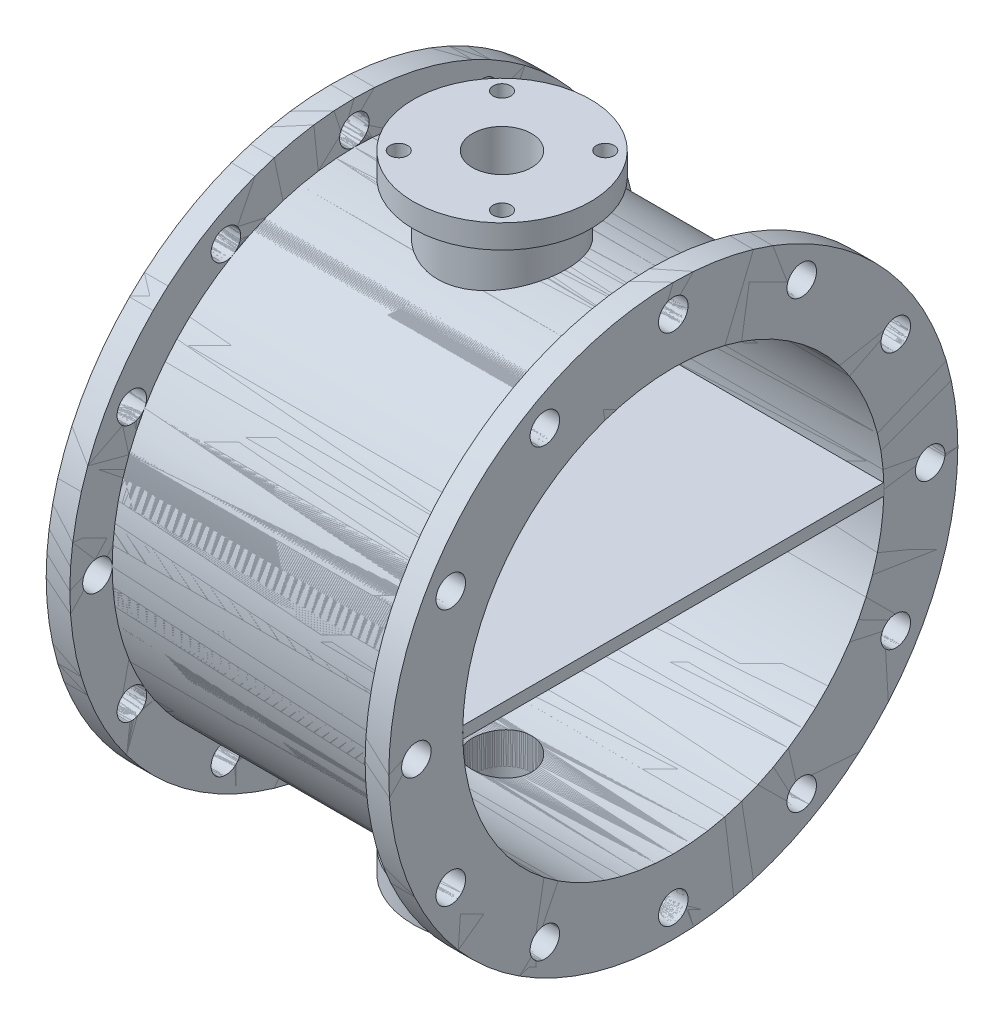
from build123d import *

# Parameters (mm, degrees)
SKETCH1_R            = 2408.838280344
SKETCH1_R_2          = 1782.540327454
SKETCH1_R_3          = 125
BOSS_EXTRUDE1_DEPTH  = 200
SKETCH2_R            = 2050
SKETCH2_R_2          = 1782.540327454
BOSS_EXTRUDE3_DEPTH  = 2500
SKETCH3_W            = 3563.677886118
SKETCH3_H            = 100
BOSS_EXTRUDE4_DEPTH  = 2900
SKETCH4_R            = 750
SKETCH4_R_2          = 75
BOSS_EXTRUDE15_DEPTH = 200
BOSS_EXTRUDE17_START = -673.261306
SKETCH11_R           = 543.142831057
SKETCH11_R_2         = 250
BOSS_EXTRUDE17_DEPTH = 473.261306
SKETCH12_R           = 250
CUT_EXTRUDE4_DEPTH   = 1310
SKETCH13_R           = 250
CUT_EXTRUDE5_DEPTH   = 1310
SKETCH14_R           = 250
CUT_EXTRUDE6_DEPTH   = 1310


with BuildPart() as part:
    # Sketch1 → Boss-Extrude1 (new body)
    with BuildSketch(Plane(origin=(0, 0, 0), x_dir=(0, 0, -1), z_dir=(1, 0, 0))):
        Circle(SKETCH1_R)
        Circle(SKETCH1_R_2, mode=Mode.SUBTRACT)
        with Locations((0, 2175)):
            Circle(SKETCH1_R_3, mode=Mode.SUBTRACT)
        with Locations((1087.5, 1883.605253231)):
            Circle(SKETCH1_R_3, mode=Mode.SUBTRACT)
        with Locations((1883.605253231, 1087.5)):
            Circle(SKETCH1_R_3, mode=Mode.SUBTRACT)
        with Locations((2175, 0)):
            Circle(SKETCH1_R_3, mode=Mode.SUBTRACT)
        with Locations((1883.605253231, -1087.5)):
            Circle(SKETCH1_R_3, mode=Mode.SUBTRACT)
        with Locations((1087.5, -1883.605253231)):
            Circle(SKETCH1_R_3, mode=Mode.SUBTRACT)
        with Locations((0, -2175)):
            Circle(SKETCH1_R_3, mode=Mode.SUBTRACT)
        with Locations((-1087.5, -1883.605253231)):
            Circle(SKETCH1_R_3, mode=Mode.SUBTRACT)
        with Locations((-1883.605253231, -1087.5)):
            Circle(SKETCH1_R_3, mode=Mode.SUBTRACT)
        with Locations((-2175, 0)):
            Circle(SKETCH1_R_3, mode=Mode.SUBTRACT)
        with Locations((-1883.605253231, 1087.5)):
            Circle(SKETCH1_R_3, mode=Mode.SUBTRACT)
        with Locations((-1087.5, 1883.605253231)):
            Circle(SKETCH1_R_3, mode=Mode.SUBTRACT)
    boss_extrude1 = extrude(amount=BOSS_EXTRUDE1_DEPTH)

    # Sketch2 → Boss-Extrude3 (add)
    with BuildSketch(Plane(origin=(200, 0, 0), x_dir=(0, 0, -1), z_dir=(1, 0, 0))):
        Circle(SKETCH2_R)
        Circle(SKETCH2_R_2, mode=Mode.SUBTRACT)
    extrude(amount=BOSS_EXTRUDE3_DEPTH)

    # Mirror2: Boss-Extrude1 across plane
    add(boss_extrude1.mirror(Plane(origin=(1450, 0, 0), x_dir=(0, 0, 1), z_dir=(1, 0, 0))))



with BuildPart() as body_2:
    # Sketch3 → Boss-Extrude4 (new body)
    with BuildSketch(Plane.ZY):
        Rectangle(SKETCH3_W, SKETCH3_H)
    extrude(amount=-BOSS_EXTRUDE4_DEPTH)


with BuildPart() as body_3:
    # Sketch4 → Boss-Extrude15 (new body)
    with BuildSketch(Plane(origin=(0, 2650, 0), x_dir=(1, 0, 0), z_dir=(0, 1, 0))):
        with Locations((1450, 0)):
            Circle(SKETCH4_R)
        with Locations((1887.092987583, 437.092987583)):
            Circle(SKETCH4_R_2, mode=Mode.SUBTRACT)
        with Locations((1887.092987583, -437.092987583)):
            Circle(SKETCH4_R_2, mode=Mode.SUBTRACT)
        with Locations((1012.907012417, -437.092987583)):
            Circle(SKETCH4_R_2, mode=Mode.SUBTRACT)
        with Locations((1012.907012417, 437.092987583)):
            Circle(SKETCH4_R_2, mode=Mode.SUBTRACT)
    extrude(amount=-BOSS_EXTRUDE15_DEPTH)


with BuildPart() as part_1:
    add(part.part)

    add(body_3.part)  # Boss-Extrude17 merges body 3
    # Sketch11 → Boss-Extrude17 (add)
    with BuildSketch(Plane(origin=(0, 2650, 0), x_dir=(1, 0, 0), z_dir=(0, 1, 0)).offset(BOSS_EXTRUDE17_START)):
        with Locations((1450, 0)):
            Circle(SKETCH11_R)
        with Locations((1450, 0)):
            Circle(SKETCH11_R_2, mode=Mode.SUBTRACT)
    extrude(amount=BOSS_EXTRUDE17_DEPTH)

    # Sketch12 → Cut-Extrude4 (cut)
    with BuildSketch(Plane(origin=(0, 2650, 0), x_dir=(1, 0, 0), z_dir=(0, 1, 0))):
        with Locations((1450, 0)):
            Circle(SKETCH12_R)
    extrude(amount=-CUT_EXTRUDE4_DEPTH, mode=Mode.SUBTRACT)


with BuildPart() as body_3_2:
    # Mirror14: mirrored copy
    add(part_1.part.mirror(Plane.ZX))

    # Sketch13 → Cut-Extrude5 (cut)
    with BuildSketch(Plane(origin=(0, 2650, 0), x_dir=(1, 0, 0), z_dir=(0, 1, 0))):
        with Locations((1450, 0)):
            Circle(SKETCH13_R)
    extrude(amount=-CUT_EXTRUDE5_DEPTH, mode=Mode.SUBTRACT)


with BuildPart() as part_2:
    add(part_1.part)

    # Sketch14 → Cut-Extrude6 (cut)
    with BuildSketch(Plane.XZ.offset(2650)):
        with Locations((1450, 0)):
            Circle(SKETCH14_R)
    extrude(amount=-CUT_EXTRUDE6_DEPTH, mode=Mode.SUBTRACT)


solid = Compound([body_2.part, body_3_2.part, part_2.part])
